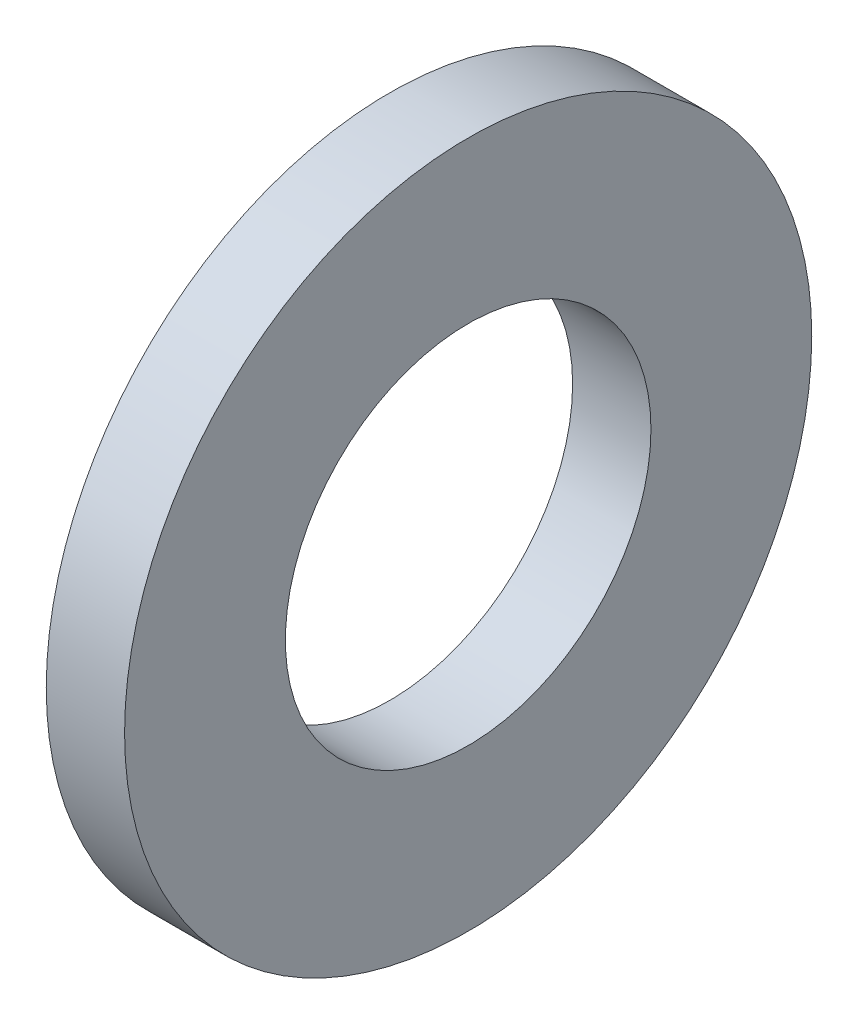
from build123d import *

# Parameters (mm, degrees)
SKETCH1_R           = 6.35
SKETCH1_R_2         = 3.3782
BOSS_EXTRUDE1_DEPTH = 1.4478


with BuildPart() as part:
    # Sketch1 → Boss-Extrude1 (new body)
    with BuildSketch(Plane(origin=(0, 0, 0), x_dir=(0, 0, -1), z_dir=(1, 0, 0))):
        Circle(SKETCH1_R)
        Circle(SKETCH1_R_2, mode=Mode.SUBTRACT)
    extrude(amount=BOSS_EXTRUDE1_DEPTH)


solid = part.part
